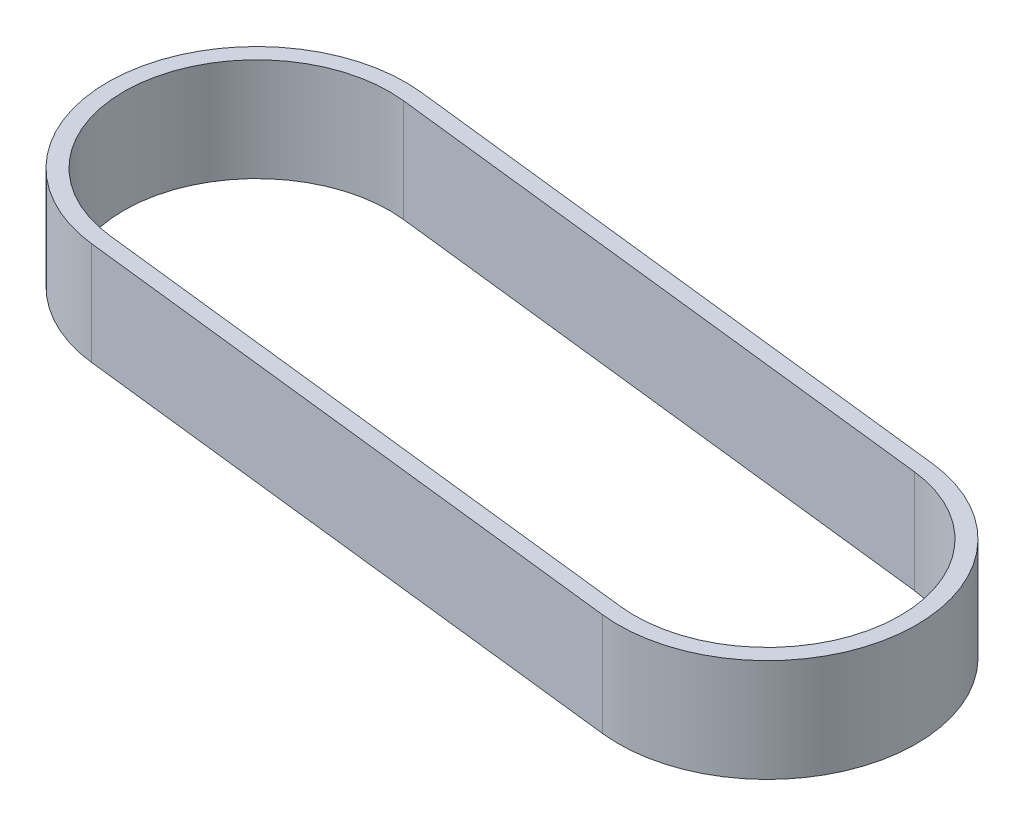
from build123d import *

# Parameters (mm, degrees)
BOSS_EXTRUDE1_DEPTH = 9.652


with BuildPart() as part:
    # Sketch1 → Boss-Extrude1 (new body)
    with BuildSketch(Plane(origin=(0, 0, 0), x_dir=(1, 0, 0), z_dir=(0, 1, 0))):
        with BuildLine():
            Line((1.584938216, 13.879800822), (55.686938216, 7.701878783))
            ThreePointArc((55.686938216, 7.701878783), (67.981800822, -7.762860255), (52.517061784, -20.05772286))
            Line((52.517061784, -20.05772286), (-1.584938216, -13.879800822))
            ThreePointArc((-1.584938216, -13.879800822), (-13.879800822, 1.584938216), (1.584938216, 13.879800822))
        make_face()
        with BuildLine():
            Line((1.412035866, 12.365640732), (55.514035866, 6.187718694))
            ThreePointArc((55.514035866, 6.187718694), (66.467640732, -7.589957904), (52.689964134, -18.54356277))
            Line((52.689964134, -18.54356277), (-1.412035866, -12.365640732))
            ThreePointArc((-1.412035866, -12.365640732), (-12.365640732, 1.412035866), (1.412035866, 12.365640732))
        make_face(mode=Mode.SUBTRACT)
    extrude(amount=BOSS_EXTRUDE1_DEPTH)


solid = part.part
